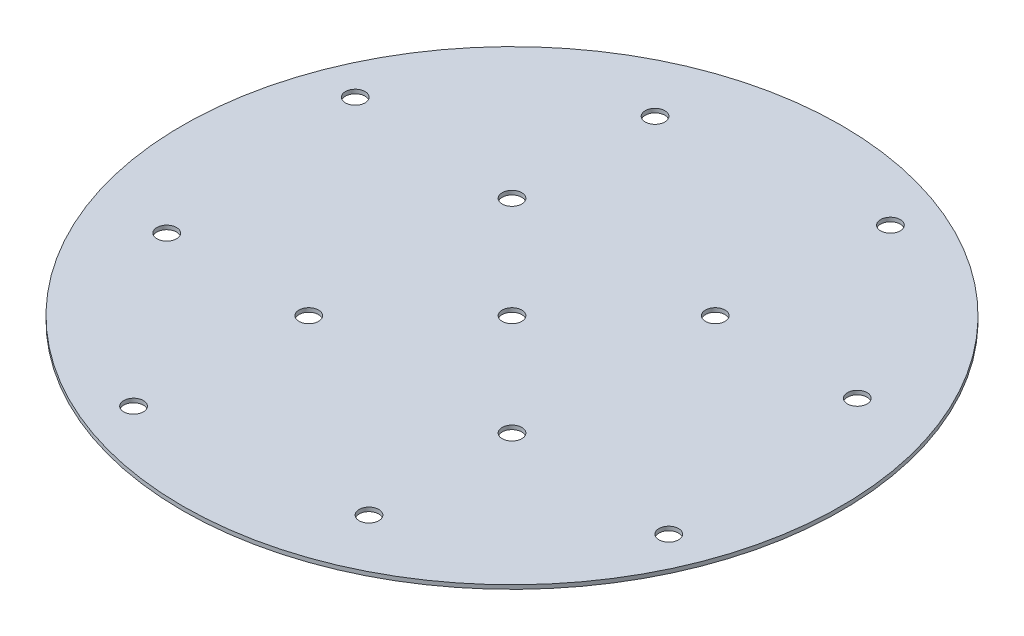
from build123d import *

# Parameters (mm, degrees)
SKETCH2_W                    = 82.55
SKETCH2_H                    = 1
F_10_0_1935_DIAMETER_HOLE1_D = 4.9149
CIRPATTERN3_COUNT            = 4
F_10_0_1935_DIAMETER_HOLE2_D = 4.9149


with BuildPart() as part:
    # Sketch2 → Revolve1 (revolve)
    with BuildSketch(Plane(origin=(0, 0, 0), x_dir=(0, 0, -1), z_dir=(1, 0, 0))):
        with Locations((-41.275, 0.5)):
            Rectangle(SKETCH2_W, SKETCH2_H)
    revolve(axis=Axis((0, -0.05, 0), (0, 1, 0)))

    # #10 (0.1935) Diameter Hole1 (through all)
    with Locations(Plane(origin=(0, 1, 0), x_dir=(1, 0, 0), z_dir=(0, 1, 0))):
        with Locations((-25.333643223, 61.160825052), (264.743675233, 73.787758551), (-67.027460084, 27.763683018), (-25.455844123, 25.455844123)):
            f_10_0_1935_diameter_hole1 = Hole(F_10_0_1935_DIAMETER_HOLE1_D / 2)

    # CirPattern3: #10 (0.1935) Diameter Hole1 ×4 about axis
    cirpattern3_axis = Axis((0, 0, 0), (0, 1, 0))
    for i in range(1, CIRPATTERN3_COUNT):
        add(f_10_0_1935_diameter_hole1.rotate(cirpattern3_axis, i * 360 / CIRPATTERN3_COUNT), mode=Mode.SUBTRACT)

    # #10 (0.1935) Diameter Hole2 (through all)
    with Locations(Plane(origin=(0, 1, 0), x_dir=(1, 0, 0), z_dir=(0, 1, 0))):
        with Locations((0, 0)):
            Hole(F_10_0_1935_DIAMETER_HOLE2_D / 2)


solid = part.part
